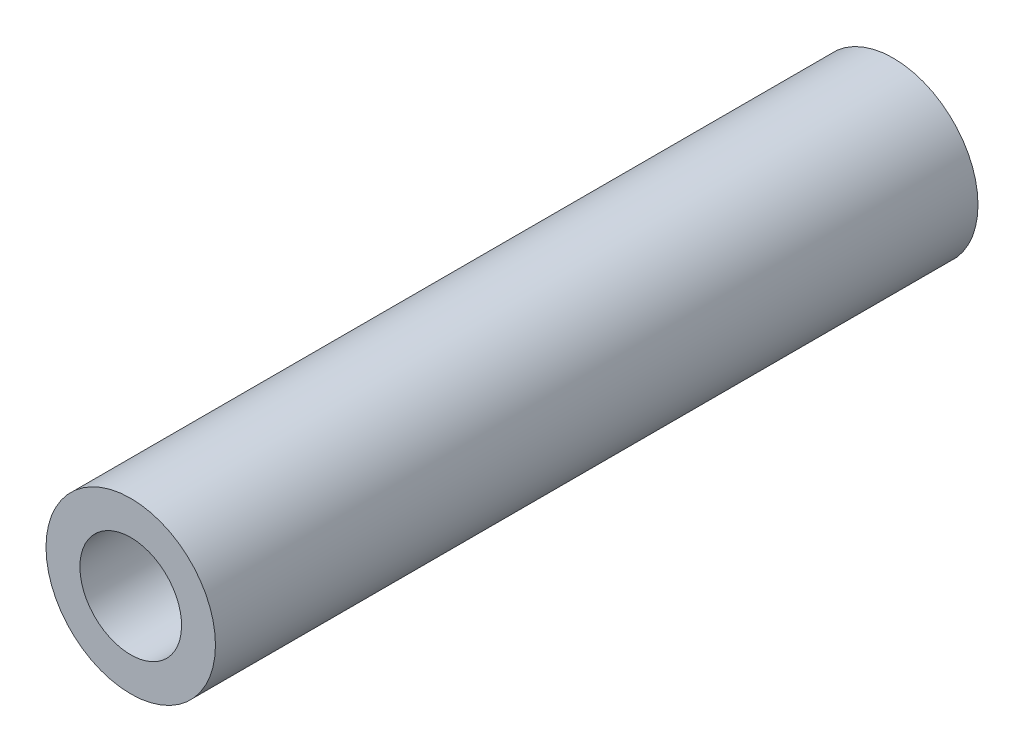
from build123d import *


with BuildPart() as part:
    # Sketch1 → Revolve1 (revolve)
    with BuildSketch(Plane(origin=(0, 0, 0), x_dir=(0, 0, -1), z_dir=(1, 0, 0))):
        Polygon((10, 0), (10, 3), (0, 3), (0, 5), (45, 5), (45, 3), (35, 3), (35, 0), align=None)
    revolve(axis=Axis((0, 0, -35), (0, 0, 1)))


solid = part.part
